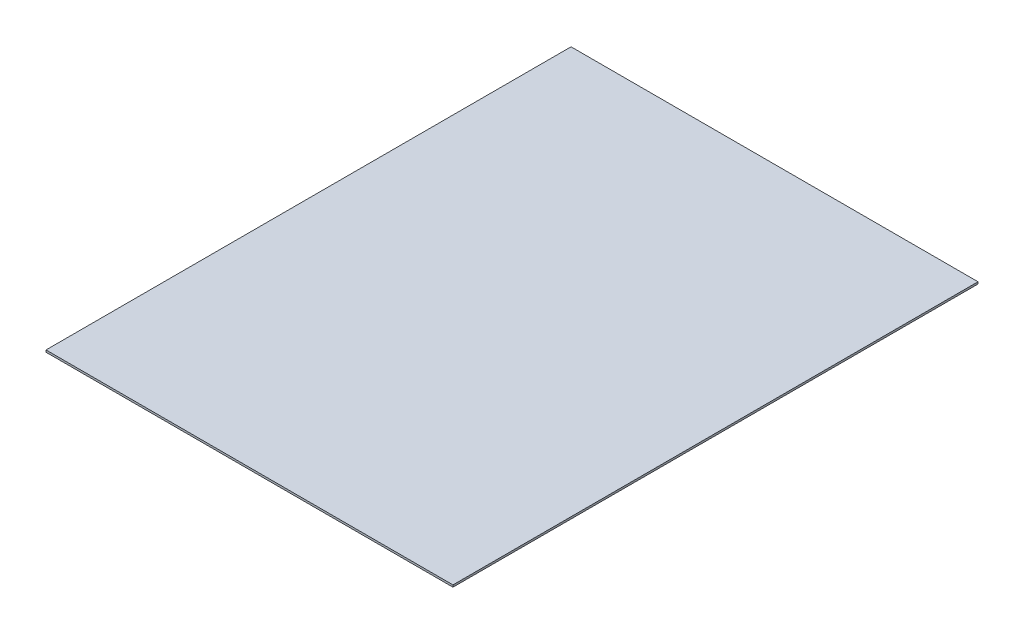
from build123d import *

# Parameters (mm, degrees)
SKETCH1_W           = 1127.125
SKETCH1_H           = 1454.15
BOSS_EXTRUDE1_DEPTH = 5.55625


with BuildPart() as part:
    # Sketch1 → Boss-Extrude1 (new body)
    with BuildSketch(Plane(origin=(0, 0, 0), x_dir=(1, 0, 0), z_dir=(0, 1, 0))):
        Rectangle(SKETCH1_W, SKETCH1_H)
    extrude(amount=BOSS_EXTRUDE1_DEPTH)


solid = part.part
